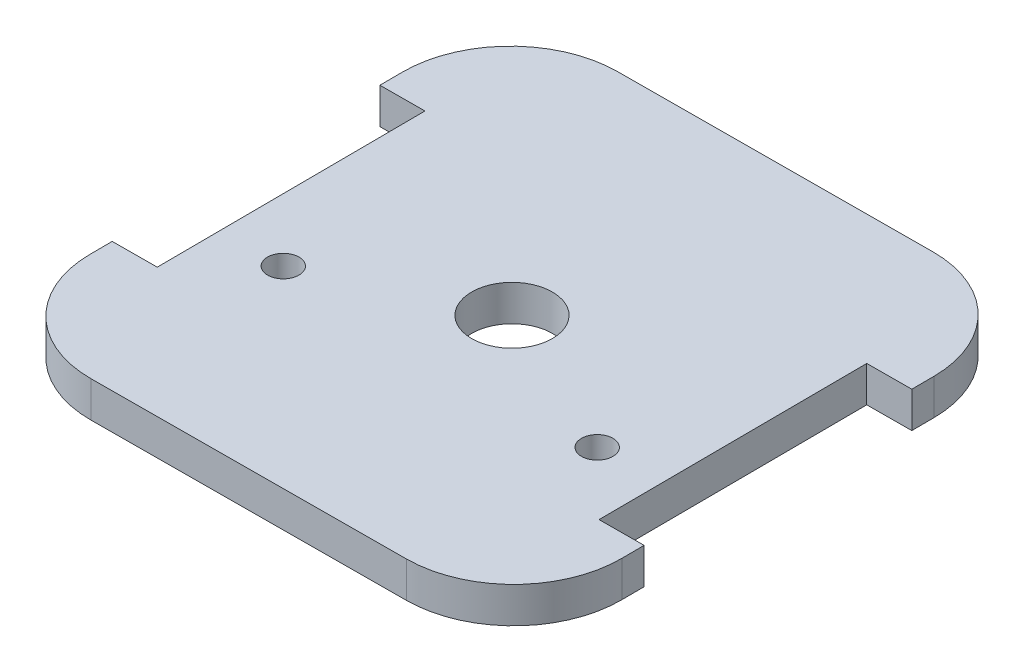
from build123d import *

# Parameters (mm, degrees)
BOSS_EXTRUDE1_DEPTH = 4
CUT_EXTRUDE2_DEPTH  = 32


with BuildPart() as part:
    # Sketch1 → Boss-Extrude1 (new body)
    with BuildSketch(Plane(origin=(0, 0, 0), x_dir=(1, 0, 0), z_dir=(0, 1, 0))):
        with BuildLine():
            Line((29.180693553, -16.120036167), (29.090421484, 1.379731001))
            Line((29.090421484, 1.379731001), (29.000149416, 18.87949817))
            ThreePointArc((29.000149416, 18.87949817), (25.441707043, 27.346536312), (16.938408224, 30.817437667))
            Line((16.938408224, 30.817437667), (-18.061126113, 30.63689353))
            ThreePointArc((-18.061126113, 30.63689353), (-26.528164255, 27.078451157), (-29.99906561, 18.575152338))
            Line((-29.99906561, 18.575152338), (-29.818521473, -16.424381999))
            ThreePointArc((-29.818521473, -16.424381999), (-26.2600791, -24.891420141), (-17.756780281, -28.362321496))
            Line((-17.756780281, -28.362321496), (17.242754056, -28.181777358))
            ThreePointArc((17.242754056, -28.181777358), (25.709792198, -24.623334986), (29.180693553, -16.120036167))
        make_face()
        with BuildLine():
            ThreePointArc((17.090813971, -8.522441914), (18.840813971, -6.772441914), (17.090813971, -5.022441914))
            ThreePointArc((17.090813971, -5.022441914), (15.340813971, -6.772441914), (17.090813971, -8.522441914))
        make_face(mode=Mode.SUBTRACT)
        with BuildLine():
            ThreePointArc((-17.909186029, -5.022441914), (-19.659186029, -6.772441914), (-17.909186029, -8.522441914))
            ThreePointArc((-17.909186029, -8.522441914), (-16.159186029, -6.772441914), (-17.909186029, -5.022441914))
        make_face(mode=Mode.SUBTRACT)
        with BuildLine():
            ThreePointArc((-0.409186029, 5.727558086), (-4.909186029, 1.227558086), (-0.409186029, -3.272441914))
            ThreePointArc((-0.409186029, -3.272441914), (4.090813971, 1.227558086), (-0.409186029, 5.727558086))
        make_face(mode=Mode.SUBTRACT)
    extrude(amount=BOSS_EXTRUDE1_DEPTH)

    # Sketch2 → Cut-Extrude2 (cut)
    with BuildSketch(Plane(origin=(0, 4, 0), x_dir=(1, 0, 0), z_dir=(0, 1, 0))):
        Polygon((-24.831482976, -13.898822811), (-24.986237153, 16.101177189), (-29.98617063, 16.07538517), (-29.831416453, -13.92461483), align=None)
        Polygon((29.167798572, -13.620268999), (29.013044396, 16.379731001), (24.013110919, 16.353938982), (24.167865096, -13.646061018), align=None)
    extrude(amount=-CUT_EXTRUDE2_DEPTH, mode=Mode.SUBTRACT)


solid = part.part
